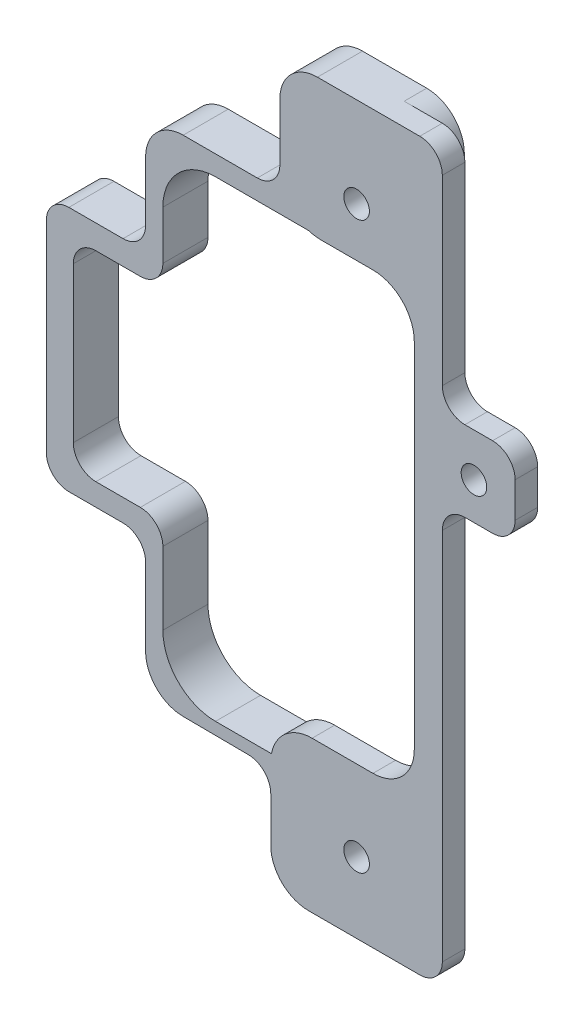
from build123d import *

# Parameters (mm, degrees)
ESQUISSE1_R             = 1.7
BOSS_EXTRU_1_DEPTH      = 3
BOSS_EXTRU_2_DEPTH      = 3
BOSS_EXTRU_2_DEPTH_BACK = 3
ESQUISSE2_R             = 5.2


with BuildPart() as part:
    # Esquisse1 → Boss.-Extru.1 (new body)
    with BuildSketch(Plane.XY):
        with BuildLine():
            Line((-117.680084405, 66.939310237), (-117.680084405, 59.695120061))
            ThreePointArc((-117.680084405, 59.695120061), (-116.069171702, 55.806032765), (-112.180084405, 54.195120061))
            Line((-112.180084405, 54.195120061), (-105.294175096, 54.195120061))
            ThreePointArc((-105.294175096, 54.195120061), (-101.4050878, 52.584207358), (-99.794175096, 48.695120061))
            Line((-99.794175096, 48.695120061), (-99.794175096, 35.930823665))
            Line((-99.794175096, 35.930823665), (-99.794175096, 12.910007682))
            Line((-99.794175096, 12.910007682), (-99.794175096, 1.692208933))
            ThreePointArc((-99.794175096, 1.692208933), (-101.4050878, -2.196878364), (-105.294175096, -3.807791067))
            Line((-105.294175096, -3.807791067), (-113.390601299, -3.807791067))
            ThreePointArc((-113.390601299, -3.807791067), (-117.279688595, -5.418703771), (-118.890601299, -9.307791067))
            Line((-118.890601299, -9.307791067), (-118.890601299, -18.42196685))
            ThreePointArc((-118.890601299, -18.42196685), (-117.279688595, -22.311054147), (-113.390601299, -23.92196685))
            Line((-113.390601299, -23.92196685), (-99.794175096, -23.92196685))
            Line((-99.794175096, -23.92196685), (-99.063687308, -23.92196685))
            ThreePointArc((-99.063687308, -23.92196685), (-96.942366965, -23.043287194), (-96.063687308, -20.92196685))
            Line((-96.063687308, -20.92196685), (-96.063687308, 28.805298211))
            ThreePointArc((-96.063687308, 28.805298211), (-95.185007652, 30.926618554), (-93.063687308, 31.805298211))
            Line((-93.063687308, 31.805298211), (-89.37766128, 31.805298211))
            ThreePointArc((-89.37766128, 31.805298211), (-87.256340937, 32.683977867), (-86.37766128, 34.805298211))
            Line((-86.37766128, 34.805298211), (-86.37766128, 39.478876094))
            ThreePointArc((-86.37766128, 39.478876094), (-87.256340937, 41.600196437), (-89.37766128, 42.478876094))
            Line((-89.37766128, 42.478876094), (-93.063687308, 42.478876094))
            ThreePointArc((-93.063687308, 42.478876094), (-95.185007652, 43.35755575), (-96.063687308, 45.478876094))
            Line((-96.063687308, 45.478876094), (-96.063687308, 69.719310237))
            ThreePointArc((-96.063687308, 69.719310237), (-96.942366965, 71.840630581), (-99.063687308, 72.719310237))
            Line((-99.063687308, 72.719310237), (-112.180084405, 72.719310237))
            ThreePointArc((-112.180084405, 72.719310237), (-116.069171702, 71.108397534), (-117.680084405, 67.219310237))
            Line((-117.680084405, 67.219310237), (-117.680084405, 66.939310237))
        make_face()
        with Locations((-91.856378892, 36.719310237)):
            Circle(ESQUISSE1_R, mode=Mode.SUBTRACT)
        with Locations((-107.466378892, -14.520689763)):
            Circle(ESQUISSE1_R, mode=Mode.SUBTRACT)
        with Locations((-107.466378892, 60.719310237)):
            Circle(ESQUISSE1_R, mode=Mode.SUBTRACT)
    extrude(amount=BOSS_EXTRU_1_DEPTH)

    # Esquisse2 → Boss.-Extru.2 (add, two sides: drawn at the far end of the back side and taken through both)
    with BuildSketch(Plane(origin=(0, 0, 0), x_dir=(-1, 0, 0), z_dir=(0, 0, -1)).offset(-BOSS_EXTRU_2_DEPTH_BACK)):
        with BuildLine():
            Line((121.867659056, -9.94673926), (130.584615963, -9.880075131))
            ThreePointArc((130.584615963, -9.880075131), (134.095405897, -8.402210456), (135.546378892, -4.880221341))
            Line((135.546378892, -4.880221341), (135.546378892, 5.415623015))
            ThreePointArc((135.546378892, 5.415623015), (136.425058549, 7.536943358), (138.546378892, 8.415623015))
            Line((138.546378892, 8.415623015), (145.752654566, 8.415623015))
            ThreePointArc((145.752654566, 8.415623015), (147.87397491, 9.294302671), (148.752654566, 11.415623015))
            Line((148.752654566, 11.415623015), (148.752654566, 38.179170847))
            ThreePointArc((148.752654566, 38.179170847), (147.87397491, 40.300491191), (145.752654566, 41.179170847))
            Line((145.752654566, 41.179170847), (138.546378892, 41.179170847))
            ThreePointArc((138.546378892, 41.179170847), (136.425058549, 42.057850504), (135.546378892, 44.179170847))
            Line((135.546378892, 44.179170847), (135.546378892, 52.099902349))
            ThreePointArc((135.546378892, 52.099902349), (134.081912798, 55.635436255), (130.546378892, 57.099902349))
            Line((130.546378892, 57.099902349), (120.680084405, 57.099902349))
            ThreePointArc((120.680084405, 57.099902349), (118.558764062, 57.978582005), (117.680084405, 60.099902349))
            Line((117.680084405, 60.099902349), (117.680084405, 67.719310237))
            ThreePointArc((117.680084405, 67.719310237), (116.215618311, 71.254844143), (112.680084405, 72.719310237))
            Line((112.680084405, 72.719310237), (104.136677999, 72.719310237))
            ThreePointArc((104.136677999, 72.719310237), (100.601144093, 71.254844143), (99.136677999, 67.719310237))
            Line((99.136677999, 67.719310237), (99.136677999, 59.456292263))
            ThreePointArc((99.136677999, 59.456292263), (100.601144093, 55.920758357), (104.136677999, 54.456292263))
            Line((104.136677999, 54.456292263), (126.246378892, 54.456292263))
            ThreePointArc((126.246378892, 54.456292263), (131.196126361, 52.406039732), (133.246378892, 47.456292263))
            Line((133.246378892, 47.456292263), (133.246378892, 40.977229779))
            ThreePointArc((133.246378892, 40.977229779), (134.125058549, 38.855909436), (136.246378892, 37.977229779))
            Line((136.246378892, 37.977229779), (142.162261637, 37.977229779))
            ThreePointArc((142.162261637, 37.977229779), (144.28358198, 37.098550123), (145.162261637, 34.977229779))
            Line((145.162261637, 34.977229779), (145.162261637, 14.363062522))
            ThreePointArc((145.162261637, 14.363062522), (144.28358198, 12.241742179), (142.162261637, 11.363062522))
            Line((142.162261637, 11.363062522), (136.246378892, 11.363062522))
            ThreePointArc((136.246378892, 11.363062522), (134.125058549, 10.484382866), (133.246378892, 8.363062522))
            Line((133.246378892, 8.363062522), (133.246378892, -1.293707737))
            ThreePointArc((133.246378892, -1.293707737), (131.196126361, -6.243455205), (126.246378892, -8.293707737))
            Line((126.246378892, -8.293707737), (104.136677999, -8.293707737))
            ThreePointArc((104.136677999, -8.293707737), (100.601144093, -9.758173831), (99.136677999, -13.293707737))
            Line((99.136677999, -13.293707737), (99.136677999, -18.92196685))
            ThreePointArc((99.136677999, -18.92196685), (100.601144093, -22.457500756), (104.136677999, -23.92196685))
            Line((104.136677999, -23.92196685), (113.890601299, -23.92196685))
            ThreePointArc((113.890601299, -23.92196685), (117.426135205, -22.457500756), (118.890601299, -18.92196685))
            Line((118.890601299, -18.92196685), (118.890601299, -12.946651534))
            ThreePointArc((118.890601299, -12.946651534), (119.761185096, -10.833458065), (121.867659056, -9.94673926))
        make_face()
        with Locations((107.466378892, -14.520689763)):
            Circle(ESQUISSE2_R, mode=Mode.SUBTRACT)
        with Locations((107.466378892, 60.719310237)):
            Circle(ESQUISSE2_R, mode=Mode.SUBTRACT)
    extrude(amount=BOSS_EXTRU_2_DEPTH + BOSS_EXTRU_2_DEPTH_BACK)


solid = part.part
